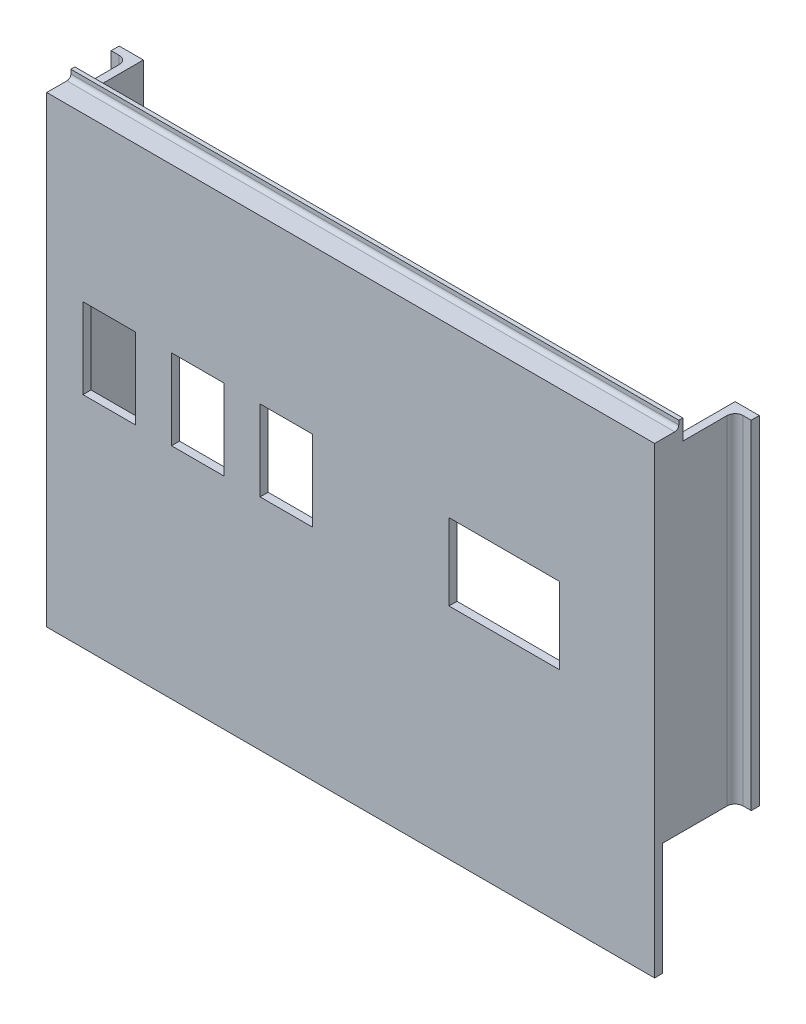
from build123d import *

# Parameters (mm, degrees)
SKETCH1_W            = 151
SKETCH1_H            = 115
BOSS_EXTRUDE1_DEPTH  = 2
SKETCH2_W            = 13
SKETCH2_H            = 20
CUT_EXTRUDE1_DEPTH   = 2
SKETCH3_W            = 27.5
SKETCH3_H            = 19
CUT_EXTRUDE2_DEPTH   = 2
SKETCH4_W            = 151
SKETCH4_H            = 3
BOSS_EXTRUDE2_DEPTH  = 4
SKETCH6_W            = 151
SKETCH6_H            = 5
BOSS_EXTRUDE3_DEPTH  = 1
FILLET1_R            = 1
SKETCH7_W            = 2
SKETCH7_H            = 84
BOSS_EXTRUDE4_DEPTH  = 10
SKETCH8_W            = 27.5
SKETCH8_H            = 19
SKETCH8_W_2          = 13
SKETCH8_H_2          = 20
CUT_EXTRUDE3_DEPTH   = 10
SKETCH9_W            = 126.512620881
SKETCH9_H            = 26.913833817
BOSS_EXTRUDE5_DEPTH  = 2
SKETCH10_W           = 2
SKETCH10_H           = 84
BOSS_EXTRUDE6_DEPTH  = 8
SKETCH12_W           = 6
SKETCH12_H           = 84
BOSS_EXTRUDE7_DEPTH  = 2
FILLET2_R            = 2
FILLET3_R            = 2
SKETCH14_W           = 57.787784132
SKETCH14_H           = 20
SKETCH14_W_2         = 59.787784131
BOSS_EXTRUDE8_DEPTH  = 2
SKETCH15_R           = 1.5
CUT_EXTRUDE4_DEPTH   = 2
BOSS_EXTRUDE9_DEPTH  = 2
BOSS_EXTRUDE10_DEPTH = 2


with BuildPart() as part:
    # Sketch1 → Boss-Extrude1 (new body)
    with BuildSketch(Plane.XY):
        with Locations((1.428458571, -7.256892256)):
            Rectangle(SKETCH1_W, SKETCH1_H)
    extrude(amount=BOSS_EXTRUDE1_DEPTH)

    # Sketch2 → Cut-Extrude1 (cut)
    with BuildSketch(Plane.XY.offset(2)):
        with Locations((-58.571541429, -29.756892256)):
            Rectangle(SKETCH2_W, SKETCH2_H)
        with Locations((-36.571541429, -29.756892256)):
            Rectangle(SKETCH2_W, SKETCH2_H)
        with Locations((-14.571541429, -29.756892256)):
            Rectangle(SKETCH2_W, SKETCH2_H)
    extrude(amount=-CUT_EXTRUDE1_DEPTH, mode=Mode.SUBTRACT)

    # Sketch3 → Cut-Extrude2 (cut)
    with BuildSketch(Plane.XY.offset(2)):
        with Locations((39.228458571, -29.756892256)):
            Rectangle(SKETCH3_W, SKETCH3_H)
    extrude(amount=-CUT_EXTRUDE2_DEPTH, mode=Mode.SUBTRACT)

    # Sketch4 → Boss-Extrude2 (add)
    with BuildSketch(Plane(origin=(0, 0, 0), x_dir=(-1, 0, 0), z_dir=(0, 0, -1))):
        with Locations((-1.428458571, 48.743107744)):
            Rectangle(SKETCH4_W, SKETCH4_H)
    extrude(amount=BOSS_EXTRUDE2_DEPTH)

    # Sketch6 → Boss-Extrude3 (add)
    with BuildSketch(Plane(origin=(0, 0, -4), x_dir=(-1, 0, 0), z_dir=(0, 0, -1))):
        with Locations((-1.428458571, 49.743107744)):
            Rectangle(SKETCH6_W, SKETCH6_H)
    extrude(amount=BOSS_EXTRUDE3_DEPTH)

    # Fillet1
    fillet1_edges = [part.edges().sort_by_distance(p)[0] for p in [
        (1.428458571, 50.243107744, -4),
    ]]
    fillet(fillet1_edges, radius=FILLET1_R)

    # Sketch7 → Boss-Extrude4 (add)
    with BuildSketch(Plane(origin=(0, 0, 0), x_dir=(-1, 0, 0), z_dir=(0, 0, -1))):
        with Locations((-75.928458571, 5.243107744)):
            Rectangle(SKETCH7_W, SKETCH7_H)
        with Locations((73.071541429, 5.243107744)):
            Rectangle(SKETCH7_W, SKETCH7_H)
    extrude(amount=BOSS_EXTRUDE4_DEPTH)

    # Sketch8 → Cut-Extrude3 (cut)
    with BuildSketch(Plane(origin=(0, 0, 0), x_dir=(-1, 0, 0), z_dir=(0, 0, -1))):
        with Locations((-39.604851179, -0.756892256)):
            Rectangle(SKETCH8_W, SKETCH8_H)
        with Locations((14.571541429, -0.256892256)):
            Rectangle(SKETCH8_W_2, SKETCH8_H_2)
        with Locations((36.571541429, -0.256892256)):
            Rectangle(SKETCH8_W_2, SKETCH8_H_2)
        with Locations((58.571541429, -0.256892256)):
            Rectangle(SKETCH8_W_2, SKETCH8_H_2)
    extrude(amount=-CUT_EXTRUDE3_DEPTH, mode=Mode.SUBTRACT)

    # Sketch9 → Boss-Extrude5 (add)
    with BuildSketch(Plane(origin=(0, 0, 0), x_dir=(-1, 0, 0), z_dir=(0, 0, -1))):
        with Locations((5.18783125, -30.15024479)):
            Rectangle(SKETCH9_W, SKETCH9_H)
    extrude(amount=-BOSS_EXTRUDE5_DEPTH)

    # Sketch10 → Boss-Extrude6 (add)
    with BuildSketch(Plane(origin=(0, 0, -10), x_dir=(-1, 0, 0), z_dir=(0, 0, -1))):
        with Locations((-75.928458571, 5.243107744)):
            Rectangle(SKETCH10_W, SKETCH10_H)
        with Locations((73.071541429, 5.243107744)):
            Rectangle(SKETCH10_W, SKETCH10_H)
    extrude(amount=BOSS_EXTRUDE6_DEPTH)

    # Sketch12 → Boss-Extrude7 (add)
    with BuildSketch(Plane(origin=(0, 0, -18), x_dir=(-1, 0, 0), z_dir=(0, 0, -1))):
        with Locations((-77.928458571, 5.243107744)):
            Rectangle(SKETCH12_W, SKETCH12_H)
        with Locations((75.071541429, 5.243107744)):
            Rectangle(SKETCH12_W, SKETCH12_H)
    extrude(amount=BOSS_EXTRUDE7_DEPTH)

    # Fillet2
    fillet2_edges = [part.edges().sort_by_distance(p)[0] for p in [
        (76.928458571, 5.243107744, -18),
    ]]
    fillet(fillet2_edges, radius=FILLET2_R)

    # Fillet3
    fillet3_edges = [part.edges().sort_by_distance(p)[0] for p in [
        (-74.071541429, 5.243107744, -18),
    ]]
    fillet(fillet3_edges, radius=FILLET3_R)

    # Sketch14 → Boss-Extrude8 (add)
    with BuildSketch(Plane(origin=(0, -36.756892256, 0), x_dir=(-1, 0, 0), z_dir=(0, -1, 0))):
        with Locations((-46.034566505, 10)):
            Rectangle(SKETCH14_W, SKETCH14_H)
        with Locations((44.177649364, 10)):
            Rectangle(SKETCH14_W_2, SKETCH14_H)
    extrude(amount=-BOSS_EXTRUDE8_DEPTH)

    # Sketch15 → Cut-Extrude4 (cut)
    with BuildSketch(Plane(origin=(0, -34.756892256, 0), x_dir=(1, 0, 0), z_dir=(0, 1, 0))):
        with Locations((46.034566505, 10)):
            Circle(SKETCH15_R)
        with Locations((-43.177649364, 10)):
            Circle(SKETCH15_R)
    extrude(amount=-CUT_EXTRUDE4_DEPTH, mode=Mode.SUBTRACT)

    # Sketch16 → Boss-Extrude9 (add)
    with BuildSketch(Plane.ZY.offset(-17.140674439)):
        Polygon((0, -34.756892256), (-20, -34.756892256), (0, -14.756892256), align=None)
    extrude(amount=-BOSS_EXTRUDE9_DEPTH)

    # Sketch18 → Boss-Extrude10 (add)
    with BuildSketch(Plane(origin=(-14.283757298, 0, 0), x_dir=(0, 0, -1), z_dir=(1, 0, 0))):
        Polygon((0, -34.756892256), (20, -34.756892256), (0, -14.756892256), align=None)
    extrude(amount=-BOSS_EXTRUDE10_DEPTH)


solid = part.part
